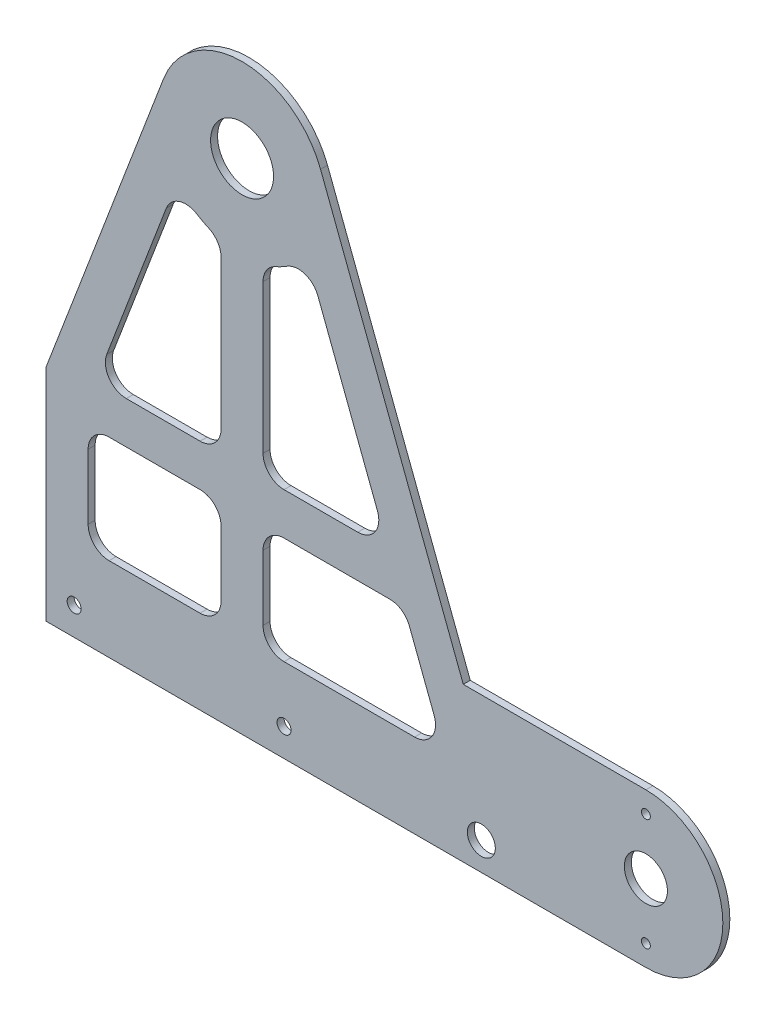
from build123d import *

# Parameters (mm, degrees)
BOSS_EXTRUDE1_DEPTH = 3.175
SKETCH2_R           = 14.2875
CUT_EXTRUDE1_DEPTH  = 4.175
SKETCH4_R           = 6.35
SKETCH4_R_2         = 3.175
CUT_EXTRUDE2_DEPTH  = 4.175
SKETCH8_R           = 9.779
BOSS_EXTRUDE3_DEPTH = 3.175
SKETCH9_R           = 2.0193
CUT_EXTRUDE3_DEPTH  = 4.175
SKETCH10_W          = 38.1
SKETCH10_H          = 100.0125
CUT_EXTRUDE4_DEPTH  = 4.175
CUT_EXTRUDE5_DEPTH  = 4.175


with BuildPart() as part:
    # Sketch1 → Boss-Extrude1 (new body)
    with BuildSketch(Plane.XY):
        with BuildLine():
            Line((-35.603982701, 119.957272705), (-127, -119.957272705))
            Line((-127, -119.957272705), (127, -119.957272705))
            Line((127, -119.957272705), (35.603982701, 119.957272705))
            ThreePointArc((35.603982701, 119.957272705), (0, 144.493850724), (-35.603982701, 119.957272705))
        make_face()
    extrude(amount=BOSS_EXTRUDE1_DEPTH)

    # Sketch2 → Cut-Extrude1 (cut, through all)
    with BuildSketch(Plane.XY.offset(3.175)):
        with Locations((0, 106.393850724)):
            Circle(SKETCH2_R)
    extrude(amount=-CUT_EXTRUDE1_DEPTH, mode=Mode.SUBTRACT)

    # Sketch4 → Cut-Extrude2 (cut, through all)
    with BuildSketch(Plane.XY.offset(3.175)):
        with Locations((108.571571229, -107.257272705)):
            Circle(SKETCH4_R)
        with Locations((-76.2, -107.257272705)):
            Circle(SKETCH4_R_2)
        with Locations((19.05, -107.257272705)):
            Circle(SKETCH4_R_2)
    extrude(amount=-CUT_EXTRUDE2_DEPTH, mode=Mode.SUBTRACT)

    # Sketch8 → Boss-Extrude3 (add)
    with BuildSketch(Plane(origin=(0, 0, 0), x_dir=(-1, 0, 0), z_dir=(0, 0, -1))):
        with BuildLine():
            Line((-127, -119.957272705), (-183.251300865, -119.957272705))
            ThreePointArc((-183.251300865, -119.957272705), (-218.176300865, -85.032272705), (-183.251300865, -50.107272705))
            Line((-183.251300865, -50.107272705), (-100.39047619, -50.107272705))
            Line((-100.39047619, -50.107272705), (-127, -119.957272705))
        make_face()
        with Locations((-183.251300865, -85.032272705)):
            Circle(SKETCH8_R, mode=Mode.SUBTRACT)
    extrude(amount=-BOSS_EXTRUDE3_DEPTH)

    # Sketch9 → Cut-Extrude3 (cut, through all)
    with BuildSketch(Plane.XY.offset(3.175)):
        with Locations((183.251300865, -59.632272705)):
            Circle(SKETCH9_R)
        with Locations((183.251300865, -110.432272705)):
            Circle(SKETCH9_R)
    extrude(amount=-CUT_EXTRUDE3_DEPTH, mode=Mode.SUBTRACT)

    # Sketch10 → Cut-Extrude4 (cut, through all)
    with BuildSketch(Plane.XY.offset(3.175)):
        with Locations((-107.95, -69.951022705)):
            Rectangle(SKETCH10_W, SKETCH10_H)
    extrude(amount=-CUT_EXTRUDE4_DEPTH, mode=Mode.SUBTRACT)

    # Sketch11 → Cut-Extrude5 (cut, through all)
    with BuildSketch(Plane.XY.offset(3.175)):
        with BuildLine():
            Line((-34.41372286, 69.569766501), (-61.423985812, -1.332173746))
            ThreePointArc((-61.423985812, -1.332173746), (-60.365933576, -10.128014274), (-52.522990136, -14.248029241))
            Line((-52.522990136, -14.248029241), (-19.05, -14.248029241))
            ThreePointArc((-19.05, -14.248029241), (-12.314807909, -11.458221332), (-9.525, -4.723029241))
            Line((-9.525, -4.723029241), (-9.525, 62.74481723))
            ThreePointArc((-9.525, 62.74481723), (-11.080813247, 67.96187459), (-15.24, 71.474623928))
            ThreePointArc((-15.24, 71.474623928), (-17.877940169, 72.748802718), (-20.410181748, 74.221898949))
            ThreePointArc((-20.410181748, 74.221898949), (-28.515665768, 75.218157925), (-34.41372286, 69.569766501))
        make_face()
        with BuildLine():
            Line((19.05, -14.248029241), (52.522990136, -14.248029241))
            ThreePointArc((52.522990136, -14.248029241), (60.365933576, -10.128014274), (61.423985812, -1.332173746))
            Line((61.423985812, -1.332173746), (34.41372286, 69.569766501))
            ThreePointArc((34.41372286, 69.569766501), (28.515665768, 75.218157925), (20.410181748, 74.221898949))
            ThreePointArc((20.410181748, 74.221898949), (17.877940169, 72.748802718), (15.24, 71.474623928))
            ThreePointArc((15.24, 71.474623928), (11.080813247, 67.96187459), (9.525, 62.74481723))
            Line((9.525, 62.74481723), (9.525, -4.723029241))
            ThreePointArc((9.525, -4.723029241), (12.314807909, -11.458221332), (19.05, -14.248029241))
        make_face()
        with BuildLine():
            Line((-19.05, -33.298029241), (-60.325, -33.298029241))
            ThreePointArc((-60.325, -33.298029241), (-67.060192091, -36.087837151), (-69.85, -42.823029241))
            Line((-69.85, -42.823029241), (-69.85, -72.332272705))
            ThreePointArc((-69.85, -72.332272705), (-67.060192091, -79.067464796), (-60.325, -81.857272705))
            Line((-60.325, -81.857272705), (-19.05, -81.857272705))
            ThreePointArc((-19.05, -81.857272705), (-12.314807909, -79.067464796), (-9.525, -72.332272705))
            Line((-9.525, -72.332272705), (-9.525, -42.823029241))
            ThreePointArc((-9.525, -42.823029241), (-12.314807909, -36.087837151), (-19.05, -33.298029241))
        make_face()
        with BuildLine():
            Line((9.525, -42.823029241), (9.525, -72.332272705))
            ThreePointArc((9.525, -72.332272705), (12.314807909, -79.067464796), (19.05, -81.857272705))
            Line((19.05, -81.857272705), (78.278892408, -81.857272705))
            ThreePointArc((78.278892408, -81.857272705), (86.121835848, -77.737257738), (87.179888084, -68.94141721))
            Line((87.179888084, -68.94141721), (75.938271526, -39.432173746))
            ThreePointArc((75.938271526, -39.432173746), (72.442260883, -34.980085802), (67.037275851, -33.298029241))
            Line((67.037275851, -33.298029241), (19.05, -33.298029241))
            ThreePointArc((19.05, -33.298029241), (12.314807909, -36.087837151), (9.525, -42.823029241))
        make_face()
    extrude(amount=-CUT_EXTRUDE5_DEPTH, mode=Mode.SUBTRACT)


solid = part.part
